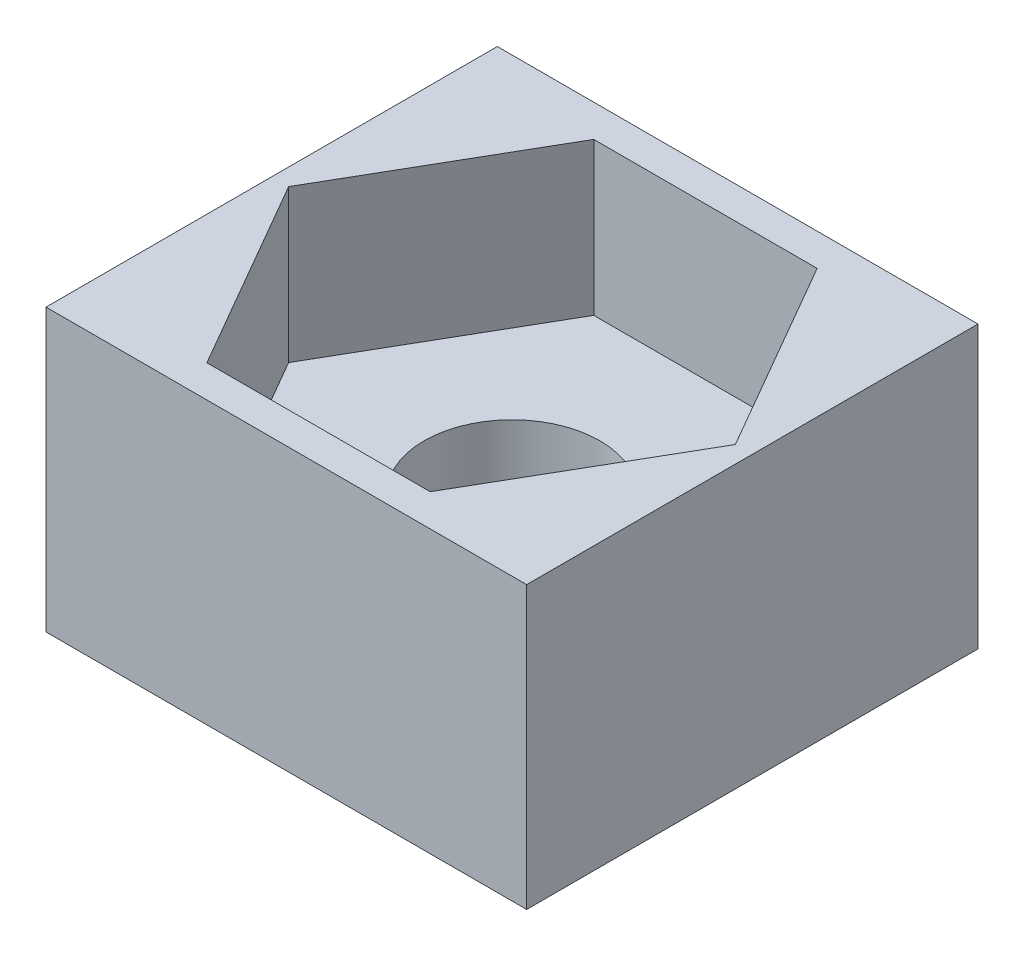
from build123d import *

# Parameters (mm, degrees)
ESQUISSE1_W        = 8.2
ESQUISSE1_H        = 7.7
BOSS_EXTRU_1_DEPTH = 4.8
ESQUISSE1_3_R      = 1.5
BOSS_EXTRU_2_DEPTH = 2.2


with BuildPart() as part:
    # Esquisse1 → Boss.-Extru.1 (new body)
    with BuildSketch(Plane(origin=(0, 0, 0), x_dir=(1, 0, 0), z_dir=(0, 1, 0))):
        Rectangle(ESQUISSE1_W, ESQUISSE1_H)
        Polygon((1.905255888, 3.3), (3.810511777, 0), (1.905255888, -3.3), (-1.905255888, -3.3), (-3.810511777, 0), (-1.905255888, 3.3), align=None, mode=Mode.SUBTRACT)
    extrude(amount=BOSS_EXTRU_1_DEPTH)

    # Esquisse1_3 → Boss.-Extru.2 (add)
    with BuildSketch(Plane(origin=(0, 0, 0), x_dir=(1, 0, 0), z_dir=(0, 1, 0))):
        Polygon((1.905255888, -3.3), (3.810511777, 0), (1.905255888, 3.3), (-1.905255888, 3.3), (-3.810511777, 0), (-1.905255888, -3.3), align=None)
        Circle(ESQUISSE1_3_R, mode=Mode.SUBTRACT)
    extrude(amount=BOSS_EXTRU_2_DEPTH)


solid = part.part
